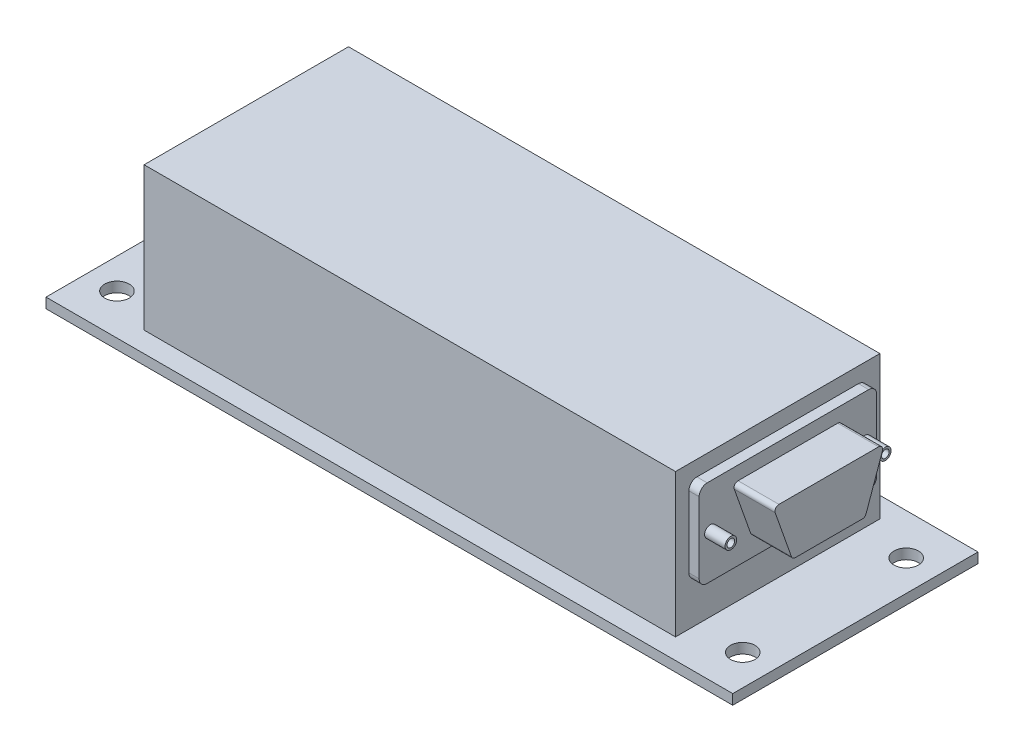
from build123d import *

# Parameters (mm, degrees)
SKETCH2_W           = 106.68
SKETCH2_H           = 38.1
BOSS_EXTRUDE1_DEPTH = 1.5748
SKETCH3_R           = 1.9
CUT_EXTRUDE1_DEPTH  = 2.5748
SKETCH4_W           = 82.55
SKETCH4_H           = 31.75
BOSS_EXTRUDE2_DEPTH = 22.2504
BOSS_EXTRUDE3_DEPTH = 1.5875
SKETCH7_R           = 0.9
SKETCH7_R_2         = 0.6
BOSS_EXTRUDE4_DEPTH = 3.175
BOSS_EXTRUDE5_DEPTH = 6.35


with BuildPart() as part:
    # Sketch2 → Boss-Extrude1 (new body)
    with BuildSketch(Plane(origin=(0, 0, 0), x_dir=(1, 0, 0), z_dir=(0, 1, 0))):
        Rectangle(SKETCH2_W, SKETCH2_H)
    extrude(amount=-BOSS_EXTRUDE1_DEPTH)

    # Sketch3 → Cut-Extrude1 (cut, through all)
    with BuildSketch(Plane(origin=(0, 0, 0), x_dir=(1, 0, 0), z_dir=(0, 1, 0))):
        with Locations((-48.635996958, 12.660327112)):
            Circle(SKETCH3_R)
        with Locations((-48.635996958, -12.731304513)):
            Circle(SKETCH3_R)
        with Locations((48.5775, 12.660327112)):
            Circle(SKETCH3_R)
        with Locations((48.5775, -12.731304513)):
            Circle(SKETCH3_R)
    extrude(amount=-CUT_EXTRUDE1_DEPTH, mode=Mode.SUBTRACT)

    # Sketch4 → Boss-Extrude2 (add)
    with BuildSketch(Plane(origin=(0, 0, 0), x_dir=(1, 0, 0), z_dir=(0, 1, 0))):
        Rectangle(SKETCH4_W, SKETCH4_H)
    extrude(amount=BOSS_EXTRUDE2_DEPTH)

    # Sketch5 → Boss-Extrude3 (add)
    with BuildSketch(Plane(origin=(41.275, 0, 0), x_dir=(0, 0, -1), z_dir=(1, 0, 0))):
        with BuildLine():
            Line((-12.543194793, 6.326748643), (12.543194793, 6.326748643))
            ThreePointArc((12.543194793, 6.326748643), (13.427078269, 6.692865167), (13.793194793, 7.576748643))
            Line((13.793194793, 7.576748643), (13.793194793, 18.610210685))
            ThreePointArc((13.793194793, 18.610210685), (13.427078269, 19.494094161), (12.543194793, 19.860210685))
            Line((12.543194793, 19.860210685), (-12.543194793, 19.860210685))
            ThreePointArc((-12.543194793, 19.860210685), (-13.427078269, 19.494094161), (-13.793194793, 18.610210685))
            Line((-13.793194793, 18.610210685), (-13.793194793, 7.576748643))
            ThreePointArc((-13.793194793, 7.576748643), (-13.427078269, 6.692865167), (-12.543194793, 6.326748643))
        make_face()
    extrude(amount=BOSS_EXTRUDE3_DEPTH)

    # Sketch7 → Boss-Extrude4 (add)
    with BuildSketch(Plane(origin=(42.8625, 0, 0), x_dir=(0, 0, -1), z_dir=(1, 0, 0))):
        with Locations((11.961268356, 13.093479664)):
            Circle(SKETCH7_R)
        with Locations((11.961268356, 13.093479664)):
            Circle(SKETCH7_R_2, mode=Mode.SUBTRACT)
        with Locations((-12.038731644, 13.093479664)):
            Circle(SKETCH7_R)
        with Locations((-12.038731644, 13.093479664)):
            Circle(SKETCH7_R_2, mode=Mode.SUBTRACT)
    extrude(amount=BOSS_EXTRUDE4_DEPTH)

    # Sketch8 → Boss-Extrude5 (add)
    with BuildSketch(Plane(origin=(42.8625, 0, 0), x_dir=(0, 0, -1), z_dir=(1, 0, 0))):
        with BuildLine():
            Line((-8.331799028, 16.906508091), (-5.797073634, 9.718080521))
            ThreePointArc((-5.797073634, 9.718080521), (-5.568701271, 9.415761232), (-5.207643796, 9.30092052))
            Line((-5.207643796, 9.30092052), (5.207643796, 9.30092052))
            ThreePointArc((5.207643796, 9.30092052), (5.568701271, 9.415761232), (5.797073634, 9.718080521))
            Line((5.797073634, 9.718080521), (8.331799028, 16.906508091))
            ThreePointArc((8.331799028, 16.906508091), (8.252528477, 17.475405565), (7.742369189, 17.73934809))
            Line((7.742369189, 17.73934809), (-7.742369189, 17.73934809))
            ThreePointArc((-7.742369189, 17.73934809), (-8.252528477, 17.475405565), (-8.331799028, 16.906508091))
        make_face()
    extrude(amount=BOSS_EXTRUDE5_DEPTH)


solid = part.part
